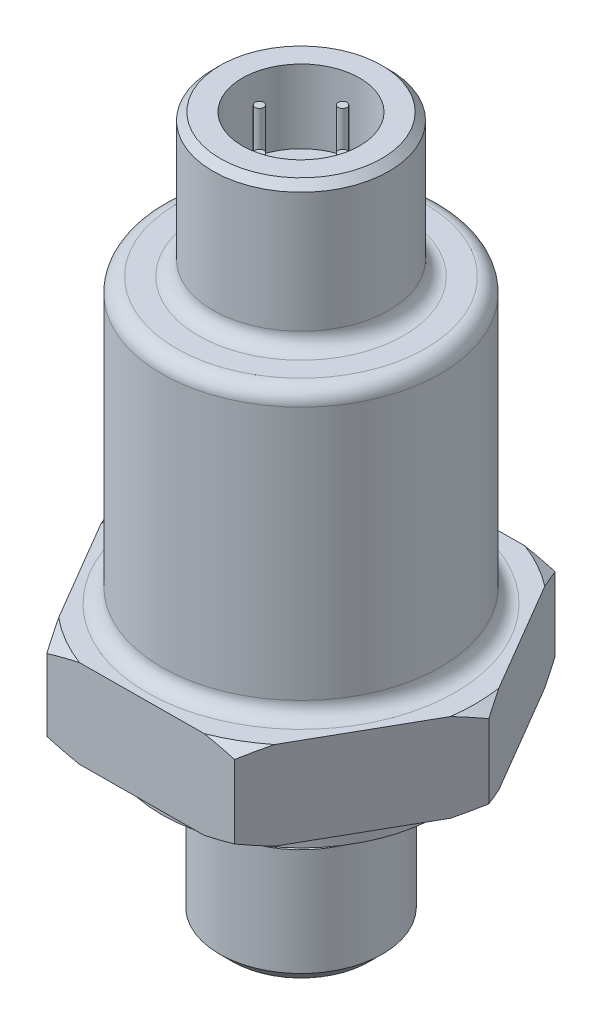
from build123d import *

# Parameters (mm, degrees)
SKETCH1_R               = 5.55625
EXTRUDE1_DEPTH          = 8.2
SKETCH2_R               = 4.6228
EXTRUDE2_DEPTH          = 2.9
SKETCH17_R              = 9.5
EXTRUDE13_DEPTH         = 1.7
EXTRUDE4_DEPTH          = 6
SKETCH5_R               = 9.5
EXTRUDE5_DEPTH          = 19.3
CHAMFER1_SIZE           = 0.9
FILLET1_R               = 1
SKETCH8_R               = 1.675
CUT_EXTRUDE1_DEPTH      = 4.9022
CUT_EXTRUDE1_DEPTH_BACK = 3.5
SKETCH14_R              = 6
EXTRUDE11_DEPTH         = 9.7
FILLET2_R               = 1
CHAMFER3_SIZE           = 0.5
SKETCH15_R              = 4
CUT_EXTRUDE2_DEPTH      = 5
SKETCH16_R              = 0.3
EXTRUDE12_DEPTH         = 4
CIRPATTERN1_COUNT       = 4


with BuildPart() as part:
    # Sketch1 → Extrude1 (new body)
    with BuildSketch(Plane(origin=(0, 0, 0), x_dir=(1, 0, 0), z_dir=(0, 1, 0))):
        with Locations(Location((0, 0, 0), (0, 0, 270))):  # turned: the seam where the file's is
            Circle(SKETCH1_R)
    extrude(amount=EXTRUDE1_DEPTH)

    # Sketch2 → Extrude2 (add)
    with BuildSketch(Plane(origin=(0, 8.2, 0), x_dir=(-1, 0, 0), z_dir=(0, 1, 0))):
        with Locations(Location((0, 0, 0), (0, 0, 90))):  # turned: the seam where the file's is
            Circle(SKETCH2_R)
    extrude(amount=EXTRUDE2_DEPTH)

    # Sketch17 → Extrude13 (add)
    with BuildSketch(Plane(origin=(0, 11.1, 0), x_dir=(-1, 0, 0), z_dir=(0, 1, 0))):
        with Locations(Location((0, 0, 0), (0, 0, 90))):  # turned: the seam where the file's is
            Circle(SKETCH17_R)
    extrude(amount=EXTRUDE13_DEPTH)

    # Sketch4 → Extrude4 (add)
    with BuildSketch(Plane(origin=(0, 12.8, 0), x_dir=(-1, 0, 0), z_dir=(0, 1, 0))):
        Polygon((12.701367758, 0.092684398), (6.270416836, 11.046049341), (-6.430950923, 10.953364943), (-12.701367758, -0.092684398), (-6.270416836, -11.046049341), (6.430950923, -10.953364943), align=None)
    extrude(amount=EXTRUDE4_DEPTH)

    # Sketch5 → Extrude5 (add)
    with BuildSketch(Plane(origin=(0, 18.8, 0), x_dir=(-1, 0, 0), z_dir=(0, 1, 0))):
        with Locations(Location((0, 0, 0), (0, 0, 90))):  # turned: the seam where the file's is
            Circle(SKETCH5_R)
    extrude(amount=EXTRUDE5_DEPTH)

    # Chamfer1
    chamfer1_edges = [part.edges().sort_by_distance(p)[0] for p in [
        (0, 0, -5.55625),
    ]]
    chamfer(chamfer1_edges, length=CHAMFER1_SIZE)

    # Fillet1
    fillet1_edges = [part.edges().sort_by_distance(p)[0] for p in [
        (0, 18.8, -9.5),
        (0, 38.1, -9.5),
    ]]
    fillet(fillet1_edges, radius=FILLET1_R)

    # Sketch7 → Cut-Revolve1 (revolve, cut)
    with BuildSketch(Plane.XY):
        Polygon((-12.701367758, 18.8), (-12.701367758, 18.222649731), (-11.701367758, 18.8), align=None)
        Polygon((-12.701367758, 12.8), (-12.701367758, 13.377350269), (-11.701367758, 12.8), align=None)
    revolve(axis=Axis((0.080267043, 18.8, 0), (0, -1, 0)), mode=Mode.SUBTRACT)

    # Sketch8 → Cut-Extrude1 (cut, two sides)
    with BuildSketch(Plane.XZ) as cut_extrude1_sk:
        with Locations(Location((0, 0, 0), (0, 0, 270))):  # turned: the seam where the file's is
            Circle(SKETCH8_R)
    extrude(amount=CUT_EXTRUDE1_DEPTH, mode=Mode.SUBTRACT)
    extrude(cut_extrude1_sk.sketch, amount=-CUT_EXTRUDE1_DEPTH_BACK, mode=Mode.SUBTRACT)

    # Sketch14 → Extrude11 (add)
    with BuildSketch(Plane(origin=(0, 38.1, 0), x_dir=(-1, 0, 0), z_dir=(0, 1, 0))):
        with Locations(Location((0, 0, 0), (0, 0, 90))):  # turned: the seam where the file's is
            Circle(SKETCH14_R)
    extrude(amount=EXTRUDE11_DEPTH)

    # Fillet2
    fillet2_edges = [part.edges().sort_by_distance(p)[0] for p in [
        (0, 38.1, -6),
    ]]
    fillet(fillet2_edges, radius=FILLET2_R)

    # Chamfer3
    chamfer3_edges = [part.edges().sort_by_distance(p)[0] for p in [
        (0, 47.8, -6),
    ]]
    chamfer(chamfer3_edges, length=CHAMFER3_SIZE)

    # Sketch15 → Cut-Extrude2 (cut)
    with BuildSketch(Plane(origin=(0, 47.8, 0), x_dir=(-1, 0, 0), z_dir=(0, 1, 0))):
        with Locations(Location((0, 0, 0), (0, 0, 90))):  # turned: the seam where the file's is
            Circle(SKETCH15_R)
    extrude(amount=-CUT_EXTRUDE2_DEPTH, mode=Mode.SUBTRACT)

    # Sketch16 → Extrude12 (add)
    with BuildSketch(Plane(origin=(0, 42.8, 0), x_dir=(-1, 0, 0), z_dir=(0, 1, 0))):
        with Locations(Location((0, -2.829193853, 0), (0, 0, 90))):  # turned: the seam where the file's is
            Circle(SKETCH16_R)
    extrude12 = extrude(amount=EXTRUDE12_DEPTH)

    # CirPattern1: Extrude12 ×4 about axis
    cirpattern1_axis = Axis((0, 0, 0), (0, -1, 0))
    for i in range(1, CIRPATTERN1_COUNT):
        add(extrude12.rotate(cirpattern1_axis, i * 360 / CIRPATTERN1_COUNT))


solid = part.part
